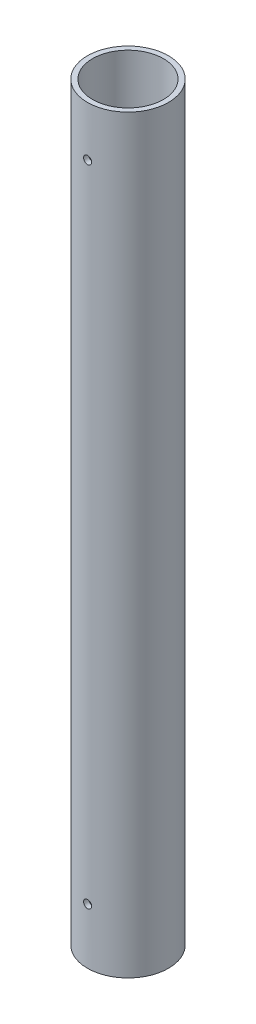
from build123d import *

# Parameters (mm, degrees)
SKETCH2_R           = 8
SKETCH2_R_2         = 7
BOSS_EXTRUDE1_DEPTH = 148.12915224
M2_TAPPED_HOLE1_D   = 1.6


with BuildPart() as part:
    # Sketch2 → Boss-Extrude1 (new body)
    with BuildSketch(Plane(origin=(0, 0, 0), x_dir=(1, 0, 0), z_dir=(0, 1, 0))):
        Circle(SKETCH2_R)
        Circle(SKETCH2_R_2, mode=Mode.SUBTRACT)
    extrude(amount=BOSS_EXTRUDE1_DEPTH)

    # M2 Tapped Hole1 (through all)
    with Locations(Plane.XY.offset(8)):
        with Locations((0, 11), (0, 138.27915224)):
            Hole(M2_TAPPED_HOLE1_D / 2)


solid = part.part
